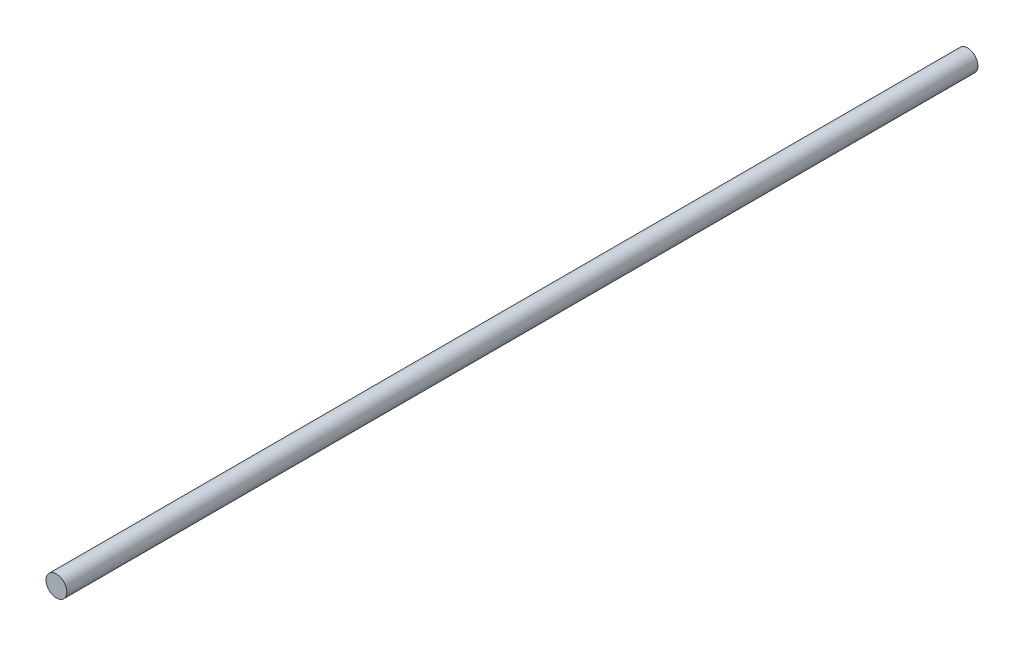
from build123d import *

# Parameters (mm, degrees)
ESBO_O1_R                = 4
RESSALTO_EXTRUS_O1_DEPTH = 350


with BuildPart() as part:
    # Esboço1 → Ressalto-extrusão1 (new body)
    with BuildSketch(Plane.XY):
        Circle(ESBO_O1_R)
    extrude(amount=RESSALTO_EXTRUS_O1_DEPTH)


solid = part.part
